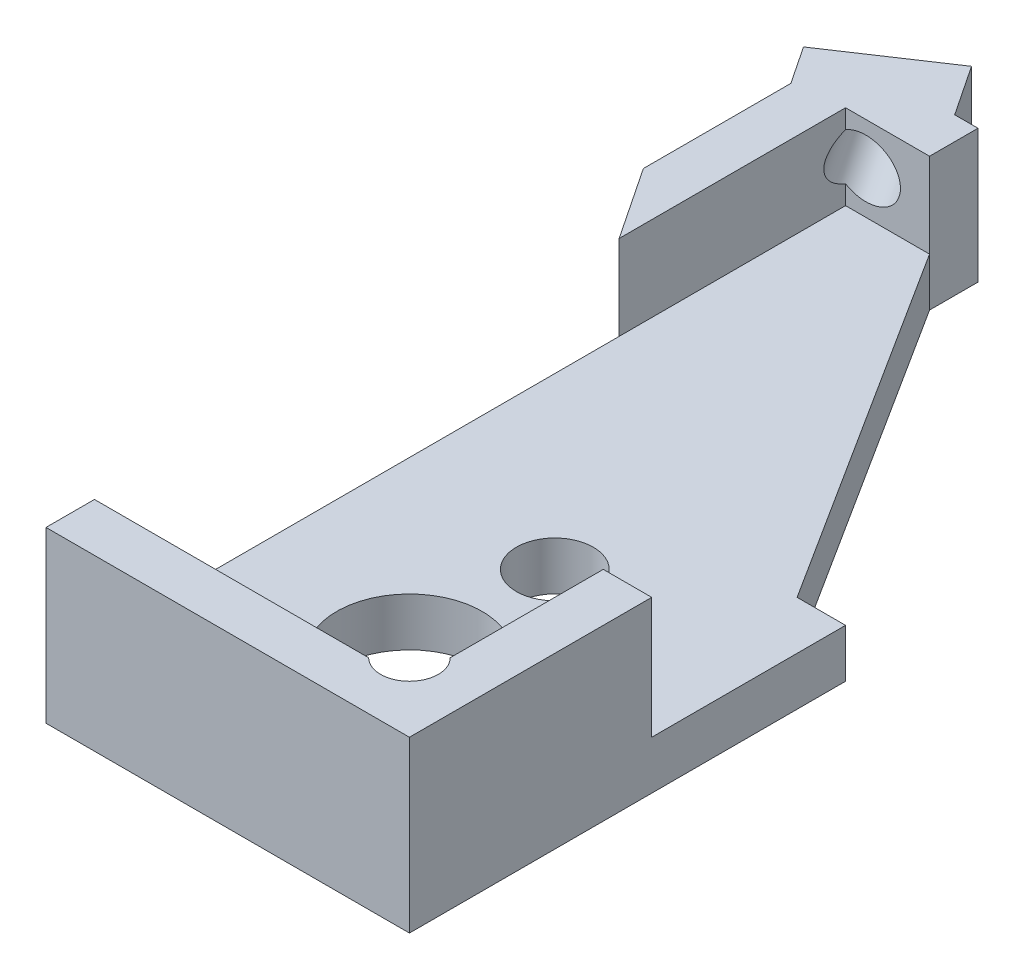
from build123d import *

# Parameters (mm, degrees)
SKETCH1_W                     = 8.5
SKETCH1_H                     = 17.5
BOSS_EXTRUDE1_DEPTH           = 3.5
SKETCH2_W                     = 6.5
SKETCH2_H                     = 15.5
CUT_EXTRUDE1_DEPTH            = 2.5
SKETCH3_R                     = 1.5
CUT_EXTRUDE2_DEPTH            = 2
SKETCH6_R                     = 0.5953125
CUT_EXTRUDE5_DEPTH            = 2.5
SKETCH7_R                     = 0.79375
CUT_EXTRUDE6_DEPTH            = 2
BOSS_EXTRUDE2_DEPTH           = 3.5
SKETCH14_W                    = 6.011083366
SKETCH14_H                    = 10.896717754
CUT_EXTRUDE8_DEPTH            = 0.75
TAP_DRILL_FOR_0_80_TAP1_D     = 1.19126
TAP_DRILL_FOR_0_80_TAP1_DEPTH = 7.11
TAP_DRILL_FOR_0_80_TAP1_TIP   = 0.357890611
CUT_EXTRUDE7_REACH            = 5.5
SKETCH15_W                    = 1
SKETCH15_H                    = 4
CUT_EXTRUDE9_DEPTH            = 2.5


with BuildPart() as part:
    # Sketch1 → Boss-Extrude1 (new body)
    with BuildSketch(Plane(origin=(0, 0, 0), x_dir=(1, 0, 0), z_dir=(0, 1, 0))):
        Rectangle(SKETCH1_W, SKETCH1_H)
    extrude(amount=BOSS_EXTRUDE1_DEPTH)

    # Sketch2 → Cut-Extrude1 (cut)
    with BuildSketch(Plane(origin=(0, 3.5, 0), x_dir=(1, 0, 0), z_dir=(0, 1, 0))):
        Rectangle(SKETCH2_W, SKETCH2_H)
    extrude(amount=-CUT_EXTRUDE1_DEPTH, mode=Mode.SUBTRACT)

    # Sketch3 → Cut-Extrude2 (cut, through all)
    with BuildSketch(Plane(origin=(0, 1, 0), x_dir=(1, 0, 0), z_dir=(0, 1, 0))):
        with Locations((0.25, -4.75)):
            Circle(SKETCH3_R)
    extrude(amount=-CUT_EXTRUDE2_DEPTH, mode=Mode.SUBTRACT)

    # Sketch6 → Cut-Extrude5 (cut)
    with BuildSketch(Plane(origin=(0, 3.5, 0), x_dir=(1, 0, 0), z_dir=(0, 1, 0))):
        with Locations((2.829050494, -7.329050494)):
            Circle(SKETCH6_R)
    extrude(amount=-CUT_EXTRUDE5_DEPTH, mode=Mode.SUBTRACT)

    # Sketch7 → Cut-Extrude6 (cut, through all)
    with BuildSketch(Plane(origin=(0, 1, 0), x_dir=(1, 0, 0), z_dir=(0, 1, 0))):
        with Locations((0.25, -1.75)):
            Circle(SKETCH7_R)
        with Locations((-1.625, -6.5)):
            Circle(SKETCH7_R)
        with Locations((2.125, -6.5)):
            Circle(SKETCH7_R)
    extrude(amount=-CUT_EXTRUDE6_DEPTH, mode=Mode.SUBTRACT)

    # Sketch9 → Boss-Extrude2 (add)
    with BuildSketch(Plane(origin=(0, 3.5, 0), x_dir=(1, 0, 0), z_dir=(0, 1, 0))):
        Polygon((-2.69064642, 9.789569053), (-4.770772156, 8.402818562), (-4.001541387, 7.248972409), (-3.411634369, 7.642243754), (-2.511322669, 8.242451554), (-1.921415651, 8.635722899), align=None)
    extrude(amount=-BOSS_EXTRUDE2_DEPTH)

    # Sketch14 → Cut-Extrude8 (cut)
    with BuildSketch(Plane(origin=(0, 3.5, 0), x_dir=(1, 0, 0), z_dir=(0, 1, 0))):
        with Locations((-3.25, 7.75)):
            Rectangle(SKETCH14_W, SKETCH14_H)
    extrude(amount=-CUT_EXTRUDE8_DEPTH, mode=Mode.SUBTRACT)

    # Tap Drill for #0-80 Tap1
    with Locations(Plane(origin=(-5.346153846, 0, -8.019230769), x_dir=(-0.832050294, 0, 0.554700196), z_dir=(-0.554700196, 0, -0.832050294))):
        with Locations((-1.941522729, 1.875)):
            Hole(TAP_DRILL_FOR_0_80_TAP1_D / 2, depth=TAP_DRILL_FOR_0_80_TAP1_DEPTH)
            with Locations((0, 0, -(TAP_DRILL_FOR_0_80_TAP1_DEPTH + TAP_DRILL_FOR_0_80_TAP1_TIP / 2))):  # 118° drill point
                Cone(0, TAP_DRILL_FOR_0_80_TAP1_D / 2, TAP_DRILL_FOR_0_80_TAP1_TIP, mode=Mode.SUBTRACT)

    # Sketch13 → Cut-Extrude7 (cut, up to next)
    with BuildSketch(Plane(origin=(0, 3.5, 0), x_dir=(1, 0, 0), z_dir=(0, 1, 0)), mode=Mode.PRIVATE) as cut_extrude7_sk1:
        Polygon((-3.249629447, -8.75), (-4.25, -8.75), (-4.25, 4.577582981), (-3.249629447, 3.077027151), align=None)
    cut_extrude7_tool1 = extrude(cut_extrude7_sk1.sketch, amount=-CUT_EXTRUDE7_REACH, mode=Mode.PRIVATE) & part.part
    add(cut_extrude7_tool1.solids().sort_by_distance((-3.759761, 3.5, 2.453888))[0], mode=Mode.SUBTRACT)
    # Sketch13 → Cut-Extrude7 (cut, up to next)
    with BuildSketch(Plane(origin=(0, 3.5, 0), x_dir=(1, 0, 0), z_dir=(0, 1, 0)), mode=Mode.PRIVATE) as cut_extrude7_sk2:
        Polygon((3.25, 0.25), (-1.517086772, 7.75), (-1.517086772, 8.75), (4.25, 8.75), (4.25, 0.25), align=None)
    cut_extrude7_tool2 = extrude(cut_extrude7_sk2.sketch, amount=-CUT_EXTRUDE7_REACH, mode=Mode.PRIVATE) & part.part
    add(cut_extrude7_tool2.solids().sort_by_distance((2.109513, 3.5, -5.504506))[0], mode=Mode.SUBTRACT)

    # Sketch15 → Cut-Extrude9 (cut)
    with BuildSketch(Plane(origin=(0, 3.5, 0), x_dir=(1, 0, 0), z_dir=(0, 1, 0))):
        with Locations((3.75, -1.75)):
            Rectangle(SKETCH15_W, SKETCH15_H)
    extrude(amount=-CUT_EXTRUDE9_DEPTH, mode=Mode.SUBTRACT)


solid = part.part
